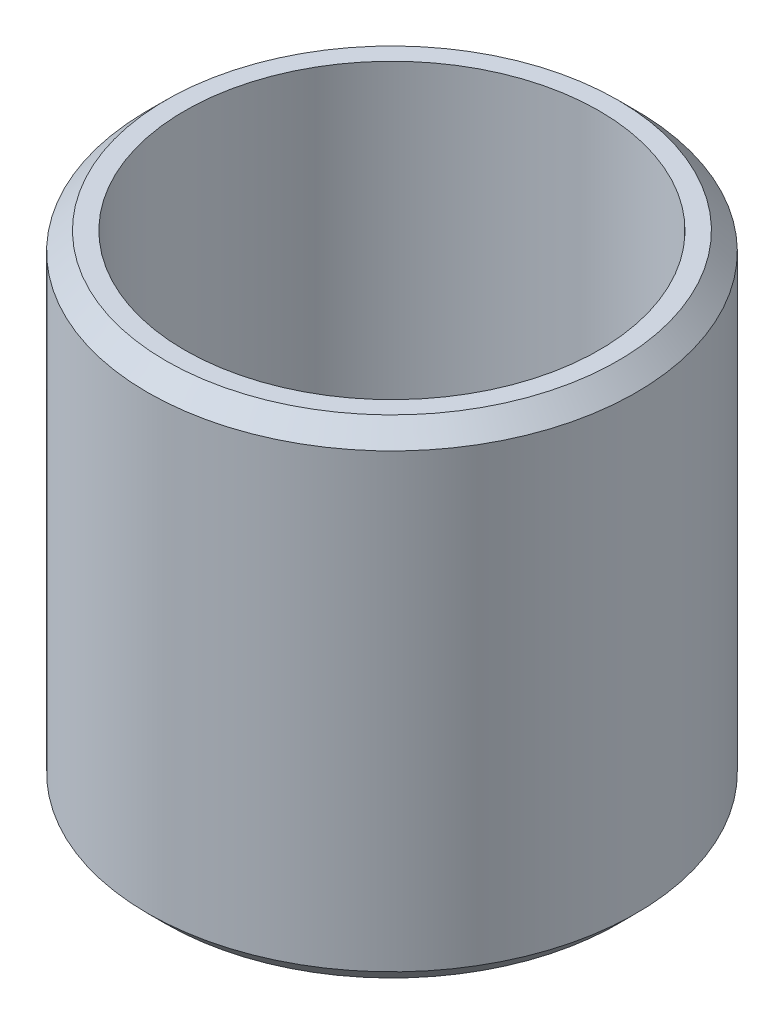
from build123d import *

# Parameters (mm, degrees)
SKETCH1_R            = 20.032
SKETCH1_R_2          = 17
EXTRUDE1_DEPTH       = 20
BUSHING_CHAMFER_SIZE = 1.5


with BuildPart() as part:
    # Sketch1 → Extrude1 (new body, symmetric)
    with BuildSketch(Plane(origin=(0, 0, 0), x_dir=(1, 0, 0), z_dir=(0, 1, 0))):
        Circle(SKETCH1_R)
        Circle(SKETCH1_R_2, mode=Mode.SUBTRACT)
    extrude(amount=EXTRUDE1_DEPTH, both=True)

    # Bushing Chamfer
    bushing_chamfer_edges = [part.edges().sort_by_distance(p)[0] for p in [
        (-20.032, -20, 0),
        (-20.032, 20, 0),
    ]]
    chamfer(bushing_chamfer_edges, length=BUSHING_CHAMFER_SIZE)


solid = part.part
